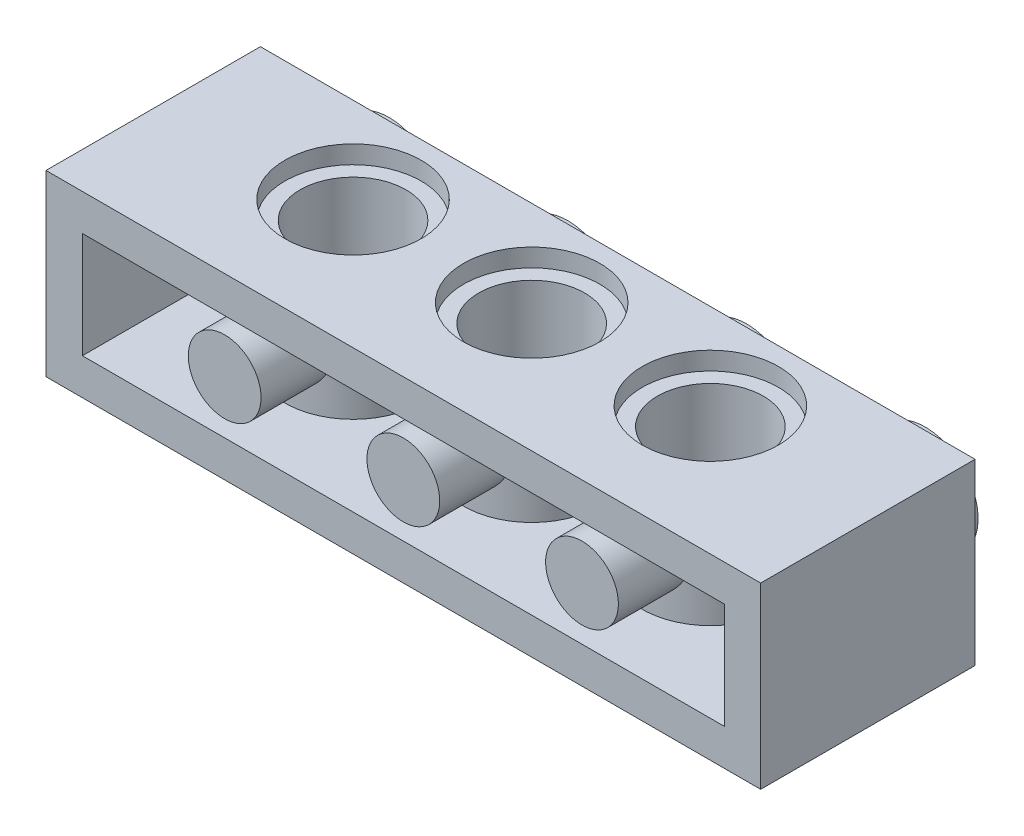
from build123d import *

# Parameters (mm, degrees)
SKETCH1_W                = 32.26
SKETCH1_H                = 9.678
BOSS_EXTRUDE1_DEPTH      = 8.065
SKETCH2_W                = 28.975
SKETCH2_H                = 4.78
CUT_EXTRUDE1_DEPTH       = 8.0355
BOSS_EXTRUDE2_DEPTH      = 4.78
BOSS_EXTRUDE3_DEPTH      = 4.78
BOSS_EXTRUDE4_DEPTH      = 4.78
SKETCH6_W                = 2.39
SKETCH6_H                = 1.78
SKETCH7_W                = 2.39
SKETCH7_H                = 1.78
SKETCH8_W                = 2.39
SKETCH8_H                = 1.78
SKETCH9_W                = 2.39
SKETCH9_H                = 1.78
SKETCH13_W               = 3.195419505
SKETCH13_H               = 1.6425
SKETCH14_W               = 3.195419505
SKETCH14_H               = 1.6425
SKETCH15_W               = 3.195419505
SKETCH15_H               = 1.6425
M3_CLEARANCE_HOLE1_D     = 3.285
M3_CLEARANCE_HOLE1_DEPTH = 1.78


with BuildPart() as part:
    # Sketch1 → Boss-Extrude1 (new body)
    with BuildSketch(Plane(origin=(0, 4.0325, 0), x_dir=(-1, 0, 0), z_dir=(0, 1, 0))):
        Rectangle(SKETCH1_W, SKETCH1_H)
    extrude(amount=-BOSS_EXTRUDE1_DEPTH)

    # Sketch2 → Cut-Extrude1 (cut)
    with BuildSketch(Plane.XY.offset(4.839)):
        Rectangle(SKETCH2_W, SKETCH2_H)
    extrude(amount=-CUT_EXTRUDE1_DEPTH, mode=Mode.SUBTRACT)

    # Sketch3 → Boss-Extrude2 (add)
    with BuildSketch(Plane.XZ.offset(-2.39)):
        with BuildLine():
            Line((10.171130278, -3.1965), (5.958869722, -3.1965))
            ThreePointArc((5.958869722, -3.1965), (8.065, 2.119), (10.171130278, -3.1965))
        make_face()
    extrude(amount=BOSS_EXTRUDE2_DEPTH)

    # Sketch4 → Boss-Extrude3 (add)
    with BuildSketch(Plane.XZ.offset(-2.39)):
        with BuildLine():
            Line((2.106130278, -3.1965), (-2.106130278, -3.1965))
            ThreePointArc((-2.106130278, -3.1965), (0, 2.119), (2.106130278, -3.1965))
        make_face()
    extrude(amount=BOSS_EXTRUDE3_DEPTH)

    # Sketch5 → Boss-Extrude4 (add)
    with BuildSketch(Plane.XZ.offset(-2.39)):
        with BuildLine():
            Line((-5.958869722, -3.1965), (-10.171130278, -3.1965))
            ThreePointArc((-10.171130278, -3.1965), (-8.065, 2.119), (-5.958869722, -3.1965))
        make_face()
    extrude(amount=BOSS_EXTRUDE4_DEPTH)

    # Sketch6 → Revolve1 (revolve)
    with BuildSketch(Plane.XZ):
        with Locations((13.2925, -5.729)):
            Rectangle(SKETCH6_W, SKETCH6_H)
    revolve(axis=Axis((12.0975, 0, -4.839), (0, 0, -1)))

    # Sketch7 → Revolve2 (revolve)
    with BuildSketch(Plane.XZ):
        with Locations((5.2275, -5.729)):
            Rectangle(SKETCH7_W, SKETCH7_H)
    revolve(axis=Axis((4.0325, 0, -4.839), (0, 0, -1)))

    # Sketch8 → Revolve3 (revolve)
    with BuildSketch(Plane.XZ):
        with Locations((-2.8375, -5.729)):
            Rectangle(SKETCH8_W, SKETCH8_H)
    revolve(axis=Axis((-4.0325, 0, -4.839), (0, 0, -1)))

    # Sketch9 → Revolve4 (revolve)
    with BuildSketch(Plane.XZ):
        with Locations((-10.9025, -5.729)):
            Rectangle(SKETCH9_W, SKETCH9_H)
    revolve(axis=Axis((-12.0975, 0, -4.839), (0, 0, -1)))

    # Sketch10 → Cut-Revolve1 (revolve, cut)
    with BuildSketch(Plane(origin=(0, 0, -0.956), x_dir=(-1, 0, 0), z_dir=(0, 0, -1))):
        Polygon((-11.14, -4.0325), (-8.065, -4.0325), (-8.065, 4.0325), (-11.14, 4.0325), (-11.14, 3.2175), (-10.455, 3.2175), (-10.455, -3.2175), (-11.14, -3.2175), align=None)
    revolve(axis=Axis((8.065, -4.0325, -0.956), (0, 1, 0)), mode=Mode.SUBTRACT)

    # Sketch11 → Cut-Revolve2 (revolve, cut)
    with BuildSketch(Plane(origin=(0, 0, -0.956), x_dir=(-1, 0, 0), z_dir=(0, 0, -1))):
        Polygon((-3.075, -4.0325), (0, -4.0325), (0, 4.0325), (-3.075, 4.0325), (-3.075, 3.2175), (-2.39, 3.2175), (-2.39, -3.2175), (-3.075, -3.2175), align=None)
    revolve(axis=Axis((0, -4.0325, -0.956), (0, 1, 0)), mode=Mode.SUBTRACT)

    # Sketch12 → Cut-Revolve3 (revolve, cut)
    with BuildSketch(Plane(origin=(0, 0, -0.956), x_dir=(-1, 0, 0), z_dir=(0, 0, -1))):
        Polygon((4.99, -4.0325), (8.065, -4.0325), (8.065, 4.0325), (4.99, 4.0325), (4.99, 3.2175), (5.675, 3.2175), (5.675, -3.2175), (4.99, -3.2175), align=None)
    revolve(axis=Axis((-8.065, -4.0325, -0.956), (0, 1, 0)), mode=Mode.SUBTRACT)

    # Sketch13 → Revolve5 (revolve)
    with BuildSketch(Plane(origin=(-8.065, 0, 0), x_dir=(0, 0, -1), z_dir=(1, 0, 0))):
        with Locations((-3.241290248, 0.82125)):
            Rectangle(SKETCH13_W, SKETCH13_H)
    revolve(axis=Axis((-8.065, 0, 4.839), (0, 0, -1)))

    # Sketch14 → Revolve6 (revolve)
    with BuildSketch(Plane(origin=(0, 0, 0), x_dir=(0, 0, -1), z_dir=(1, 0, 0))):
        with Locations((-3.241290248, 0.82125)):
            Rectangle(SKETCH14_W, SKETCH14_H)
    revolve(axis=Axis((0, 0, 4.839), (0, 0, -1)))

    # Sketch15 → Revolve7 (revolve)
    with BuildSketch(Plane(origin=(8.065, 0, 0), x_dir=(0, 0, -1), z_dir=(1, 0, 0))):
        with Locations((-3.241290248, 0.82125)):
            Rectangle(SKETCH15_W, SKETCH15_H)
    revolve(axis=Axis((8.065, 0, 4.839), (0, 0, -1)))

    # M3 Clearance Hole1
    with Locations(Plane(origin=(0, 0, -6.619), x_dir=(-1, 0, 0), z_dir=(0, 0, -1))):
        with Locations((12.0975, 0), (4.0325, 0), (-4.0325, 0), (-12.0975, 0)):
            Hole(M3_CLEARANCE_HOLE1_D / 2, depth=M3_CLEARANCE_HOLE1_DEPTH)


solid = part.part
